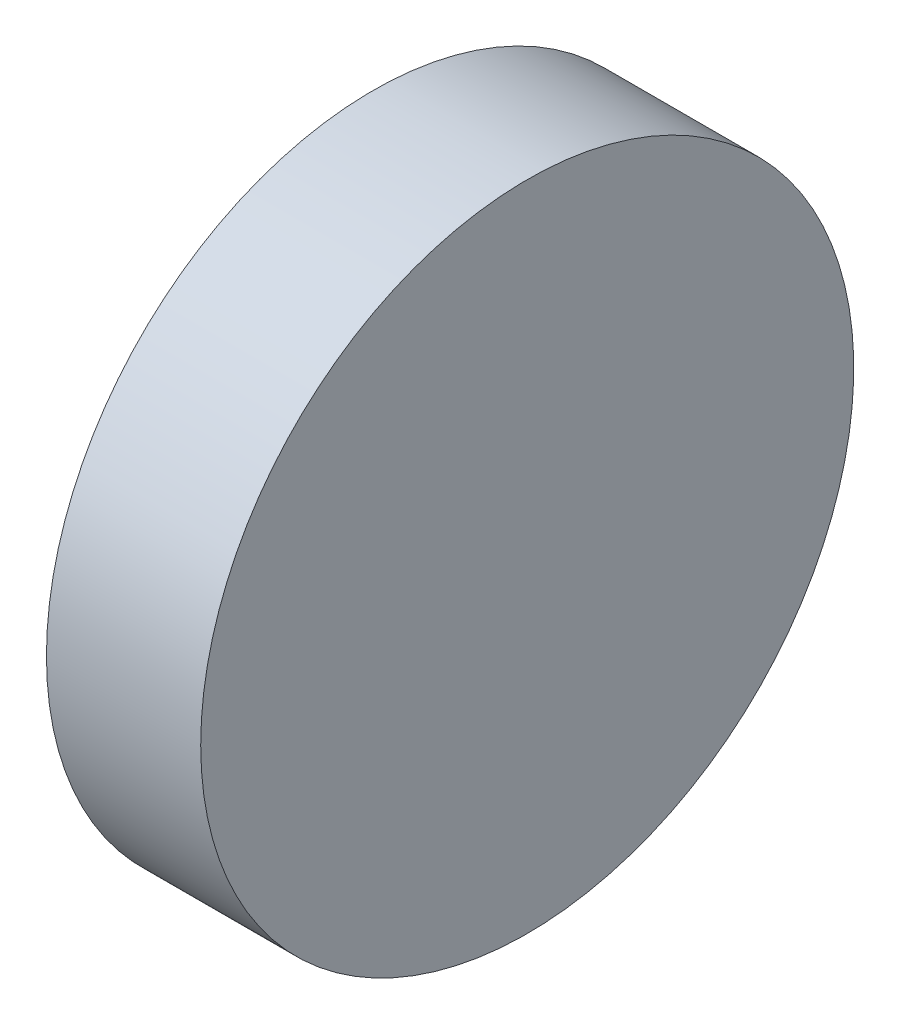
from build123d import *

# Parameters (mm, degrees)
SKETCH_1_W = 6
SKETCH_1_H = 12.7


with BuildPart() as part:
    # 草图1 → 旋转1 (revolve)
    with BuildSketch(Plane.XY, mode=Mode.PRIVATE) as revolve_1_sk:
        with Locations((262.724352893, 83.643179349)):
            Rectangle(SKETCH_1_W, SKETCH_1_H)
    revolve(revolve_1_sk.sketch.rotate(Axis((254.000801993, 77.293179349, 0), (1, 0, 0)), 90), axis=Axis((254.000801993, 77.293179349, 0), (1, 0, 0)))  # turned: the seam where the file's is


solid = part.part
